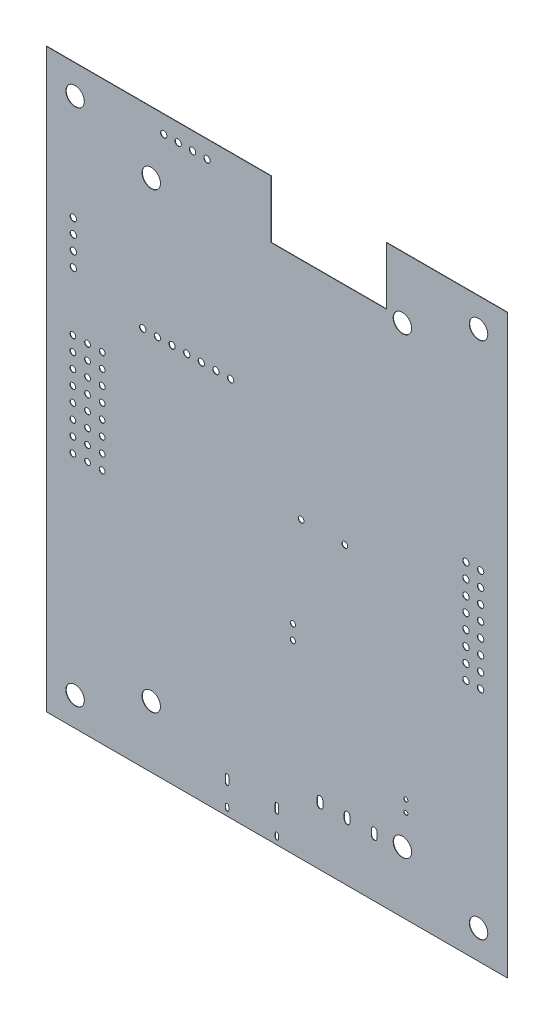
from build123d import *

# Parameters (mm, degrees)
SKETCH_2_R      = 40.64516129
SKETCH_2_R_2    = 40.640064516
SKETCH_2_R_3    = 13.970322581
SKETCH_2_R_4    = 8.890322581
SKETCH_2_R_5    = 12.7
SKETCH_2_R_6    = 13.970322577
SKETCH_2_R_7    = 11.612903226
EXTRUDE_1_DEPTH = 1.6


with BuildPart() as part:
    # 草图2 → 凸台-拉伸1 (new body)
    with BuildSketch(Plane.XY):
        Polygon((2032.004064516, -2540.005096774), (0, -2540.005096774), (0, 0), (990.602, 0), (990.602, -254.000516129), (1498.602967742, -254.000516129), (1498.602967742, 0), (2032.004064516, 0), align=None)
        with Locations((462.534903226, -2268.224516144)):
            Circle(SKETCH_2_R, mode=Mode.SUBTRACT)
        with Locations((127.000258065, -2413.00483871)):
            Circle(SKETCH_2_R_2, mode=Mode.SUBTRACT)
        with Locations((1905.003806452, -2413.00483871)):
            Circle(SKETCH_2_R_2, mode=Mode.SUBTRACT)
        with Locations((1569.46916129, -2270.764516129)):
            Circle(SKETCH_2_R, mode=Mode.SUBTRACT)
        with Locations((1905.003806452, -127.000258065)):
            Circle(SKETCH_2_R_2, mode=Mode.SUBTRACT)
        with Locations((1569.46916129, -271.780516129)):
            Circle(SKETCH_2_R, mode=Mode.SUBTRACT)
        with Locations((462.534903226, -271.780516144)):
            Circle(SKETCH_2_R, mode=Mode.SUBTRACT)
        with Locations((127.000258065, -127.000258065)):
            Circle(SKETCH_2_R, mode=Mode.SUBTRACT)
        with Locations((517.65483871, -77.419354839)):
            Circle(SKETCH_2_R_3, mode=Mode.SUBTRACT)
        with Locations((1584.597677419, -2133.510451611)):
            Circle(SKETCH_2_R_4, mode=Mode.SUBTRACT)
        with Locations((1584.597677419, -2082.710451611)):
            Circle(SKETCH_2_R_4, mode=Mode.SUBTRACT)
        with Locations((1315.87483871, -1245.161290323)):
            Circle(SKETCH_2_R_5, mode=Mode.SUBTRACT)
        with Locations((1122.83483871, -1245.161290323)):
            Circle(SKETCH_2_R_5, mode=Mode.SUBTRACT)
        with Locations((812.41883871, -864.430580645)):
            Circle(SKETCH_2_R_3, mode=Mode.SUBTRACT)
        with Locations((747.902709677, -864.430580645)):
            Circle(SKETCH_2_R_3, mode=Mode.SUBTRACT)
        with Locations((683.386580645, -864.430580645)):
            Circle(SKETCH_2_R_3, mode=Mode.SUBTRACT)
        with Locations((618.870451613, -864.430580645)):
            Circle(SKETCH_2_R_3, mode=Mode.SUBTRACT)
        with Locations((554.354322581, -864.430580645)):
            Circle(SKETCH_2_R_3, mode=Mode.SUBTRACT)
        with Locations((489.838193548, -864.430580645)):
            Circle(SKETCH_2_R_3, mode=Mode.SUBTRACT)
        with Locations((425.322064516, -864.430580645)):
            Circle(SKETCH_2_R_3, mode=Mode.SUBTRACT)
        with Locations((1914.052387097, -1495.808967744)):
            Circle(SKETCH_2_R_3, mode=Mode.SUBTRACT)
        with Locations((1849.536258065, -1495.808967746)):
            Circle(SKETCH_2_R_3, mode=Mode.SUBTRACT)
        with Locations((1914.054967742, -1431.292838712)):
            Circle(SKETCH_2_R_3, mode=Mode.SUBTRACT)
        with Locations((1849.536258065, -1431.29283871)):
            Circle(SKETCH_2_R_3, mode=Mode.SUBTRACT)
        with Locations((1849.536258065, -1366.776709677)):
            Circle(SKETCH_2_R_3, mode=Mode.SUBTRACT)
        with Locations((1914.052387097, -1366.776709677)):
            Circle(SKETCH_2_R_3, mode=Mode.SUBTRACT)
        with Locations((1914.052387097, -1302.26058065)):
            Circle(SKETCH_2_R_3, mode=Mode.SUBTRACT)
        with Locations((1849.536258065, -1302.26058065)):
            Circle(SKETCH_2_R_3, mode=Mode.SUBTRACT)
        with Locations((1849.536258065, -1237.744451613)):
            Circle(SKETCH_2_R_3, mode=Mode.SUBTRACT)
        with Locations((1914.052387097, -1237.744451613)):
            Circle(SKETCH_2_R_3, mode=Mode.SUBTRACT)
        with Locations((1914.052387097, -1173.228322581)):
            Circle(SKETCH_2_R_3, mode=Mode.SUBTRACT)
        with Locations((1849.536258065, -1173.228322581)):
            Circle(SKETCH_2_R_3, mode=Mode.SUBTRACT)
        with Locations((1849.536258065, -1108.712193548)):
            Circle(SKETCH_2_R_3, mode=Mode.SUBTRACT)
        with Locations((1914.052387097, -1108.712193548)):
            Circle(SKETCH_2_R_3, mode=Mode.SUBTRACT)
        with Locations((1914.052387097, -1044.19606452)):
            Circle(SKETCH_2_R_3, mode=Mode.SUBTRACT)
        with Locations((1849.536258065, -1044.19606452)):
            Circle(SKETCH_2_R_3, mode=Mode.SUBTRACT)
        with Locations((246.320064516, -1495.808967742)):
            Circle(SKETCH_2_R_5, mode=Mode.SUBTRACT)
        with Locations((181.803935484, -1495.808967742)):
            Circle(SKETCH_2_R_5, mode=Mode.SUBTRACT)
        with Locations((117.287806452, -1495.808967739)):
            Circle(SKETCH_2_R_5, mode=Mode.SUBTRACT)
        with Locations((117.287806452, -1431.29283871)):
            Circle(SKETCH_2_R_5, mode=Mode.SUBTRACT)
        with Locations((181.803935484, -1431.29283871)):
            Circle(SKETCH_2_R_5, mode=Mode.SUBTRACT)
        with Locations((246.320064516, -1431.29283871)):
            Circle(SKETCH_2_R_5, mode=Mode.SUBTRACT)
        with Locations((246.320064516, -1366.776709677)):
            Circle(SKETCH_2_R_5, mode=Mode.SUBTRACT)
        with Locations((181.803935484, -1366.776709677)):
            Circle(SKETCH_2_R_5, mode=Mode.SUBTRACT)
        with Locations((117.287806452, -1366.776709677)):
            Circle(SKETCH_2_R_5, mode=Mode.SUBTRACT)
        with Locations((117.287806452, -1302.261225803)):
            Circle(SKETCH_2_R_5, mode=Mode.SUBTRACT)
        with Locations((181.803935484, -1302.261225803)):
            Circle(SKETCH_2_R_5, mode=Mode.SUBTRACT)
        with Locations((246.320064516, -1302.261225803)):
            Circle(SKETCH_2_R_5, mode=Mode.SUBTRACT)
        with Locations((246.320064516, -1237.745096771)):
            Circle(SKETCH_2_R_5, mode=Mode.SUBTRACT)
        with Locations((181.803935484, -1237.745096771)):
            Circle(SKETCH_2_R_5, mode=Mode.SUBTRACT)
        with Locations((117.287806452, -1237.745096771)):
            Circle(SKETCH_2_R_5, mode=Mode.SUBTRACT)
        with Locations((246.320064516, -1173.228967739)):
            Circle(SKETCH_2_R_5, mode=Mode.SUBTRACT)
        with Locations((181.803935484, -1173.228967739)):
            Circle(SKETCH_2_R_5, mode=Mode.SUBTRACT)
        with Locations((117.287806452, -1173.228967739)):
            Circle(SKETCH_2_R_5, mode=Mode.SUBTRACT)
        with Locations((117.287806452, -1108.712838706)):
            Circle(SKETCH_2_R_5, mode=Mode.SUBTRACT)
        with Locations((181.803935484, -1108.712838706)):
            Circle(SKETCH_2_R_5, mode=Mode.SUBTRACT)
        with Locations((246.320064516, -1108.712838706)):
            Circle(SKETCH_2_R_5, mode=Mode.SUBTRACT)
        with Locations((246.320064516, -1044.196709674)):
            Circle(SKETCH_2_R_5, mode=Mode.SUBTRACT)
        with Locations((181.803935484, -1044.196709674)):
            Circle(SKETCH_2_R_5, mode=Mode.SUBTRACT)
        with Locations((117.287806452, -1044.196709674)):
            Circle(SKETCH_2_R_5, mode=Mode.SUBTRACT)
        with Locations((119.35483871, -785.574193548)):
            Circle(SKETCH_2_R_3, mode=Mode.SUBTRACT)
        with Locations((119.35483871, -722.074193548)):
            Circle(SKETCH_2_R_3, mode=Mode.SUBTRACT)
        with Locations((119.354838706, -658.574193545)):
            Circle(SKETCH_2_R_6, mode=Mode.SUBTRACT)
        with Locations((119.35483871, -595.074193548)):
            Circle(SKETCH_2_R_3, mode=Mode.SUBTRACT)
        with Locations((708.15483871, -77.419354839)):
            Circle(SKETCH_2_R_3, mode=Mode.SUBTRACT)
        with Locations((644.65483871, -77.419354839)):
            Circle(SKETCH_2_R_3, mode=Mode.SUBTRACT)
        with Locations((581.15483871, -77.419354839)):
            Circle(SKETCH_2_R_3, mode=Mode.SUBTRACT)
        with Locations((1086.93, -1724.360967742)):
            Circle(SKETCH_2_R_7, mode=Mode.SUBTRACT)
        with Locations((1086.93, -1660.860967742)):
            Circle(SKETCH_2_R_7, mode=Mode.SUBTRACT)
        Polygon((1202.499355139, -2257.593195146), (1210.348386796, -2257.593195146), (1216.698386796, -2262.206740199), (1219.123870968, -2269.671612903), (1219.123870968, -2295.071612903), (1216.698386796, -2302.536485607), (1210.348386796, -2307.15003066), (1202.499355139, -2307.15003066), (1196.149355139, -2302.536485607), (1193.723870968, -2295.071612903), (1193.723870968, -2269.671612903), (1196.149355139, -2262.206740199), align=None, mode=Mode.SUBTRACT)
        Polygon((1023.794193548, -2415.707096774), (1021.562347221, -2421.095250447), (1016.174193548, -2423.327096774), (1010.786039876, -2421.095250447), (1008.554193548, -2415.707096774), (1008.554193548, -2385.227096774), (1010.786039876, -2379.838943102), (1016.174193548, -2377.607096774), (1021.562347221, -2379.838943102), (1023.794193548, -2385.227096774), align=None, mode=Mode.SUBTRACT)
        Polygon((1010.786039876, -2519.649443995), (1008.554193548, -2514.261290323), (1008.554193548, -2499.021290323), (1010.786039876, -2493.63313665), (1016.174193548, -2491.401290323), (1021.562347221, -2493.63313665), (1023.794193548, -2499.021290323), (1023.794193548, -2514.261290323), (1021.562347221, -2519.649443995), (1016.174193548, -2521.881290323), align=None, mode=Mode.SUBTRACT)
        Polygon((802.110734318, -2519.649443995), (796.722580645, -2521.881290323), (791.334426973, -2519.649443995), (789.102580645, -2514.261290323), (789.102580645, -2499.021290323), (791.334426973, -2493.63313665), (796.722580645, -2491.401290323), (802.110734318, -2493.63313665), (804.342580645, -2499.021290323), (804.342580645, -2514.261290323), align=None, mode=Mode.SUBTRACT)
        Polygon((804.342580645, -2415.707096774), (802.110734318, -2421.095250447), (796.722580645, -2423.327096774), (791.334426973, -2421.095250447), (789.102580645, -2415.707096774), (789.102580645, -2385.227096774), (791.334426973, -2379.838943102), (796.722580645, -2377.607096774), (802.110734318, -2379.838943102), (804.342580645, -2385.227096774), align=None, mode=Mode.SUBTRACT)
        Polygon((1338.503870968, -2295.071612903), (1336.078386796, -2302.536485607), (1329.728386796, -2307.15003066), (1321.879355139, -2307.15003066), (1315.529355139, -2302.536485607), (1313.103870968, -2295.071612903), (1313.103870968, -2269.671612903), (1315.529355139, -2262.206740199), (1321.879355139, -2257.593195146), (1329.728386796, -2257.593195146), (1336.078386796, -2262.206740199), (1338.503870968, -2269.671612903), align=None, mode=Mode.SUBTRACT)
        Polygon((1457.883870968, -2269.671612903), (1457.883870968, -2295.071612903), (1455.458386796, -2302.536485607), (1449.108386796, -2307.15003066), (1441.259355139, -2307.15003066), (1434.909355139, -2302.536485607), (1432.483870968, -2295.071612903), (1432.483870968, -2269.671612903), (1434.909355139, -2262.206740199), (1441.259355139, -2257.593195146), (1449.108386796, -2257.593195146), (1455.458386796, -2262.206740199), align=None, mode=Mode.SUBTRACT)
    extrude(amount=EXTRUDE_1_DEPTH)


solid = part.part
